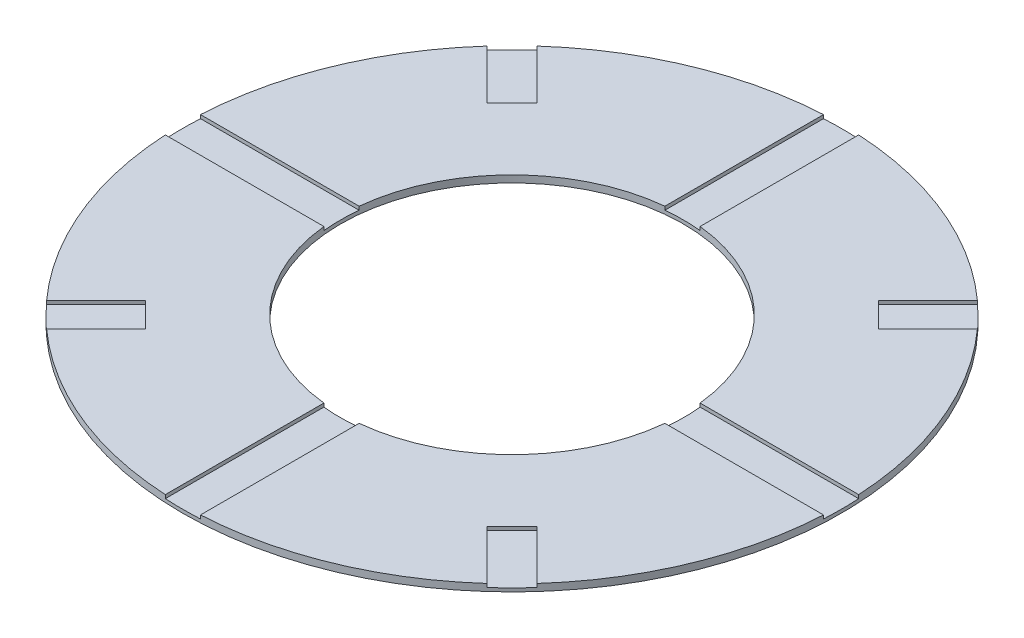
from build123d import *

# Parameters (mm, degrees)
CROQUIS2_R              = 9.365
CROQUIS2_R_2            = 4.87
SALIENTE_EXTRUIR1_DEPTH = 0.2
CORTAR_EXTRUIR1_DEPTH   = 0.1


with BuildPart() as part:
    # Croquis2 → Saliente-Extruir1 (new body)
    with BuildSketch(Plane(origin=(0, 0, 0), x_dir=(1, 0, 0), z_dir=(0, 1, 0))):
        Circle(CROQUIS2_R)
        Circle(CROQUIS2_R_2, mode=Mode.SUBTRACT)
    extrude(amount=SALIENTE_EXTRUIR1_DEPTH)

    # Croquis3 → Cortar-Extruir1 (cut)
    with BuildSketch(Plane(origin=(0, 0.2, 0), x_dir=(1, 0, 0), z_dir=(0, 1, 0))):
        with BuildLine():
            Line((-0.5, 9.351642904), (-0.5, 4.84426465))
            ThreePointArc((-0.5, 4.84426465), (0, 4.87), (0.5, 4.84426465))
            Line((0.5, 4.84426465), (0.5, 9.351642904))
            ThreePointArc((0.5, 9.351642904), (0.25008919, 9.36166013), (0, 9.365))
            ThreePointArc((0, 9.365), (-0.25008919, 9.36166013), (-0.5, 9.351642904))
        make_face()
        with BuildLine():
            ThreePointArc((0.5, -4.84426465), (0, -4.87), (-0.5, -4.84426465))
            Line((-0.5, -4.84426465), (-0.5, -9.351642904))
            ThreePointArc((-0.5, -9.351642904), (-0.25008919, -9.36166013), (0, -9.365))
            ThreePointArc((0, -9.365), (0.25008919, -9.36166013), (0.5, -9.351642904))
            Line((0.5, -9.351642904), (0.5, -4.84426465))
        make_face()
        with BuildLine():
            Line((-4.84426465, 0.5), (-9.351642904, 0.5))
            ThreePointArc((-9.351642904, 0.5), (-9.36166013, 0.25008919), (-9.365, 0))
            ThreePointArc((-9.365, 0), (-9.36166013, -0.25008919), (-9.351642904, -0.5))
            Line((-9.351642904, -0.5), (-4.84426465, -0.5))
            ThreePointArc((-4.84426465, -0.5), (-4.87, 0), (-4.84426465, 0.5))
        make_face()
        with BuildLine():
            Line((9.351642904, 0.5), (4.84426465, 0.5))
            ThreePointArc((4.84426465, 0.5), (4.863561907, 0.250330935), (4.87, 0))
            ThreePointArc((4.87, 0), (4.863561907, -0.250330935), (4.84426465, -0.5))
            Line((4.84426465, -0.5), (9.351642904, -0.5))
            ThreePointArc((9.351642904, -0.5), (9.36166013, -0.25008919), (9.365, 0))
            ThreePointArc((9.365, 0), (9.36166013, 0.25008919), (9.351642904, 0.5))
        make_face()
        with BuildLine():
            ThreePointArc((6.622055006, 6.622055006), (6.442853599, 6.796533124), (6.259056722, 6.966163503))
            Line((6.259056722, 6.966163503), (4.854288053, 5.561394834))
            Line((4.854288053, 5.561394834), (5.561394834, 4.854288053))
            Line((5.561394834, 4.854288053), (6.966163503, 6.259056722))
            ThreePointArc((6.966163503, 6.259056722), (6.796533124, 6.442853599), (6.622055006, 6.622055006))
        make_face()
        with BuildLine():
            Line((4.854288053, -5.561394834), (6.259056722, -6.966163503))
            ThreePointArc((6.259056722, -6.966163503), (6.442853599, -6.796533124), (6.622055006, -6.622055006))
            ThreePointArc((6.622055006, -6.622055006), (6.796533124, -6.442853599), (6.966163503, -6.259056722))
            Line((6.966163503, -6.259056722), (5.561394834, -4.854288053))
            Line((5.561394834, -4.854288053), (4.854288053, -5.561394834))
        make_face()
        with BuildLine():
            Line((-5.561394834, -4.854288053), (-6.966163503, -6.259056722))
            ThreePointArc((-6.966163503, -6.259056722), (-6.796533124, -6.442853599), (-6.622055006, -6.622055006))
            ThreePointArc((-6.622055006, -6.622055006), (-6.442853599, -6.796533124), (-6.259056722, -6.966163503))
            Line((-6.259056722, -6.966163503), (-4.854288053, -5.561394834))
            Line((-4.854288053, -5.561394834), (-5.561394834, -4.854288053))
        make_face()
        Polygon((-4.854288053, 5.561394834), (-5.561394834, 4.854288053), (-6.975608396, 6.268501615), (-6.268501615, 6.975608396), align=None)
    extrude(amount=-CORTAR_EXTRUIR1_DEPTH, mode=Mode.SUBTRACT)


solid = part.part
